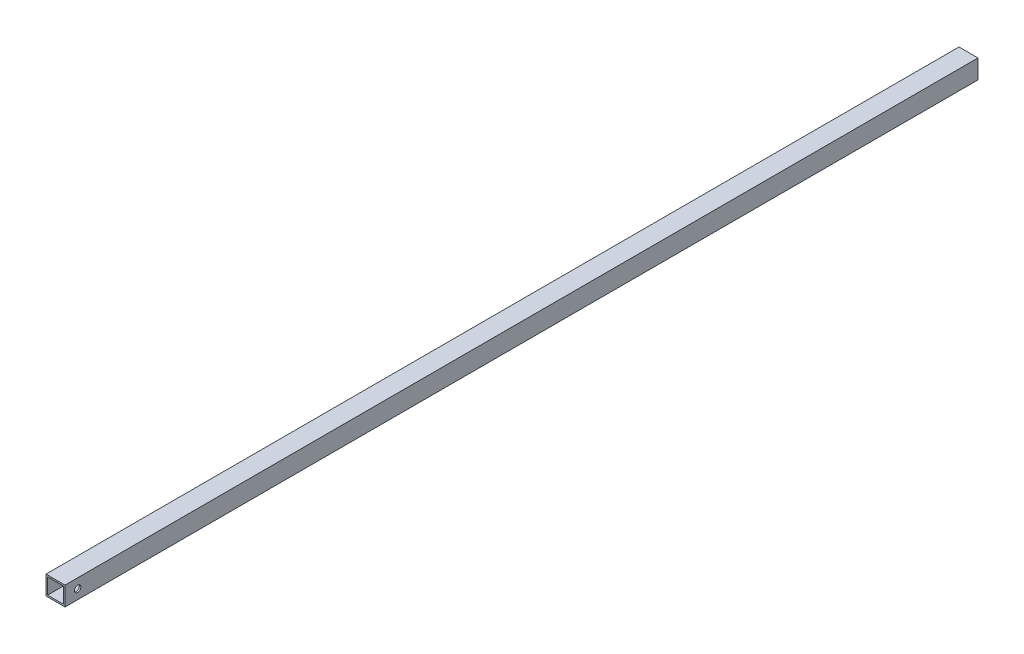
from build123d import *

# Parameters (mm, degrees)
SKETCH1_W           = 38.1
SKETCH1_H           = 38.1
SKETCH1_W_2         = 31.75
SKETCH1_H_2         = 31.75
BOSS_EXTRUDE1_DEPTH = 1828.8
SKETCH2_R           = 6.35
CUT_EXTRUDE1_DEPTH  = 38.1


with BuildPart() as part:
    # Sketch1 → Boss-Extrude1 (new body)
    with BuildSketch(Plane.XY):
        Rectangle(SKETCH1_W, SKETCH1_H)
        Rectangle(SKETCH1_W_2, SKETCH1_H_2, mode=Mode.SUBTRACT)
    extrude(amount=-BOSS_EXTRUDE1_DEPTH)

    # Sketch2 → Cut-Extrude1 (cut)
    with BuildSketch(Plane.ZY.offset(19.05)):
        with Locations((-25.4, 0)):
            Circle(SKETCH2_R)
    extrude(amount=-CUT_EXTRUDE1_DEPTH, mode=Mode.SUBTRACT)


solid = part.part
